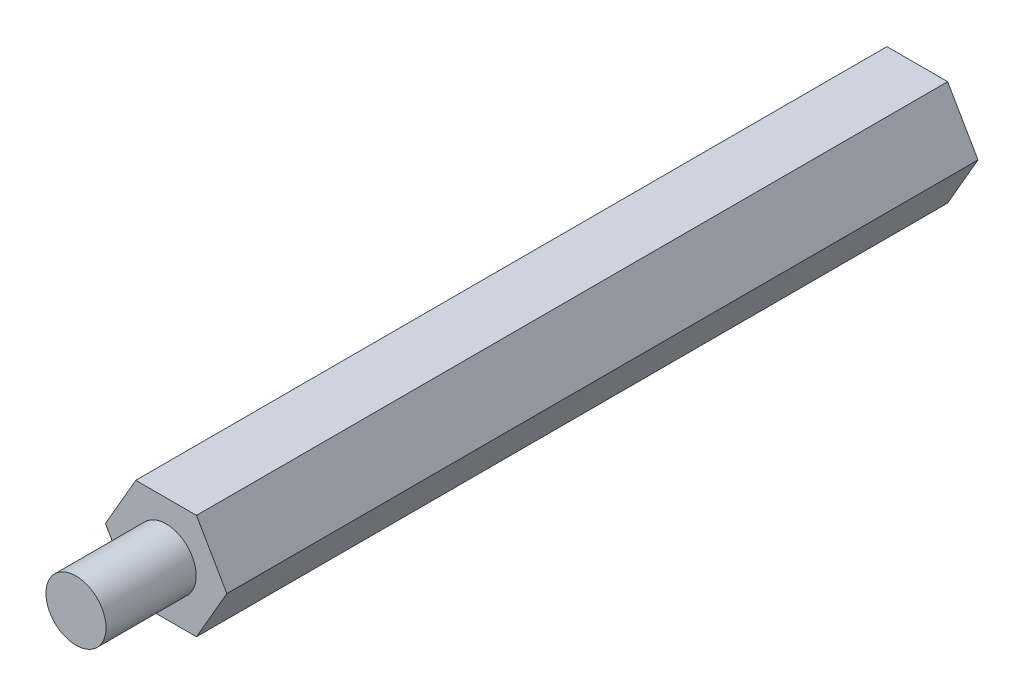
from build123d import *

# Parameters (mm, degrees)
EXTRUDE_1_DEPTH = 50
SKETCH_2_R      = 2
EXTRUDE_2_DEPTH = 6
M4X0_7_1_D      = 3.3
M4X0_7_1_DEPTH  = 10.5
M4X0_7_1_TIP    = 0.991420021


with BuildPart() as part:
    # 草圖1 → 填料-伸長1 (new body)
    with BuildSketch(Plane.XY):
        Polygon((4.041451884, 0), (2.020725942, 3.5), (-2.020725942, 3.5), (-4.041451884, 0), (-2.020725942, -3.5), (2.020725942, -3.5), align=None)
    extrude(amount=EXTRUDE_1_DEPTH)

    # 草圖2 → 填料-伸長2 (add)
    with BuildSketch(Plane.XY.offset(50)):
        Circle(SKETCH_2_R)
    extrude(amount=EXTRUDE_2_DEPTH)

    # M4x0.7 螺紋孔1
    with Locations(Plane(origin=(0, 0, 0), x_dir=(-1, 0, 0), z_dir=(0, 0, -1))):
        with Locations((0, 0)):
            Hole(M4X0_7_1_D / 2, depth=M4X0_7_1_DEPTH)
            with Locations((0, 0, -(M4X0_7_1_DEPTH + M4X0_7_1_TIP / 2))):  # 118° drill point
                Cone(0, M4X0_7_1_D / 2, M4X0_7_1_TIP, mode=Mode.SUBTRACT)


solid = part.part
